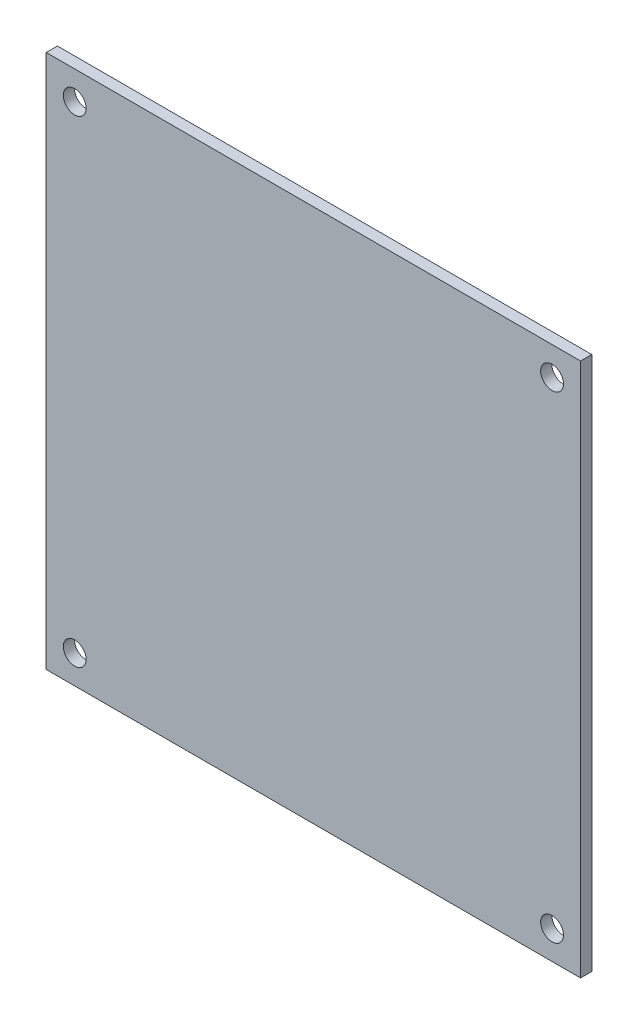
from build123d import *

# Parameters (mm, degrees)
SKETCH2_W           = 74.999999255
SKETCH2_H           = 74.999999255
SKETCH2_R           = 1.6
BOSS_EXTRUDE1_DEPTH = 1.5748


with BuildPart() as part:
    # Sketch2 → Boss-Extrude1 (new body)
    with BuildSketch(Plane.XY):
        with Locations((-25.795121523, -0.042075674)):
            Rectangle(SKETCH2_W, SKETCH2_H)
        with Locations((-59.295121471, 33.457923878)):
            Circle(SKETCH2_R, mode=Mode.SUBTRACT)
        with Locations((7.704878529, 33.457923878)):
            Circle(SKETCH2_R, mode=Mode.SUBTRACT)
        with Locations((-59.295121471, -33.542076122)):
            Circle(SKETCH2_R, mode=Mode.SUBTRACT)
        with Locations((7.704878529, -33.542076122)):
            Circle(SKETCH2_R, mode=Mode.SUBTRACT)
    extrude(amount=BOSS_EXTRUDE1_DEPTH)


solid = part.part
